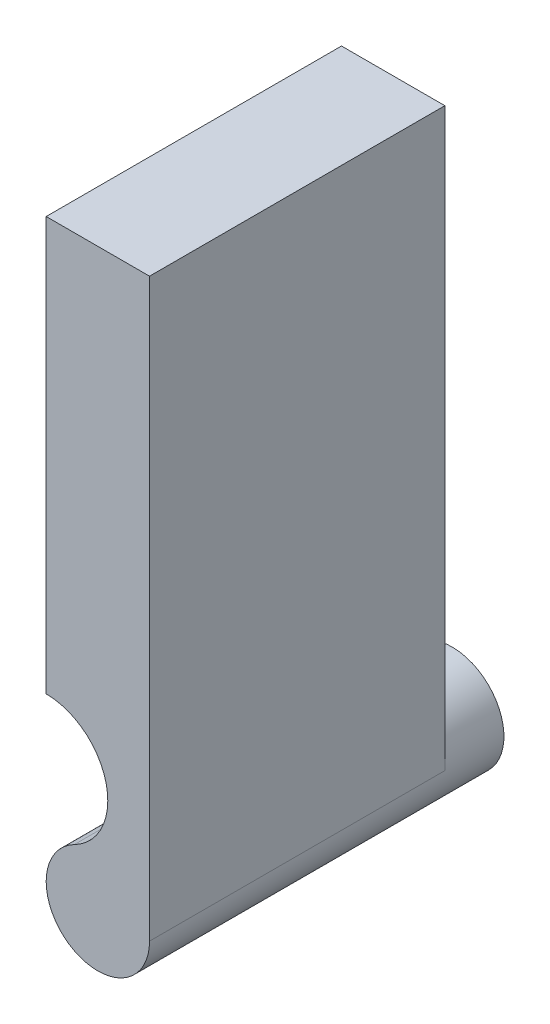
from build123d import *

# Parameters (mm, degrees)
DODANIE_WYCI_GNI_CIE1_DEPTH = 10
SZKIC2_R                    = 1.75
DODANIE_WYCI_GNI_CIE2_DEPTH = 2


with BuildPart() as part:
    # Szkic1 → Dodanie-wyciągnięcie1 (new body)
    with BuildSketch(Plane.XY):
        with BuildLine():
            Line((1.75, 0), (1.75, 19.5))
            Line((1.75, 19.5), (-1.75, 19.5))
            Line((-1.75, 19.5), (-1.75, 5.5))
            ThreePointArc((-1.75, 5.5), (0.277964608, 3.903301802), (-0.798314607, 1.557303371))
            ThreePointArc((-0.798314607, 1.557303371), (-0.912537517, -1.493243209), (1.75, 0))
        make_face()
    extrude(amount=DODANIE_WYCI_GNI_CIE1_DEPTH)

    # Szkic2 → Dodanie-wyciągnięcie2 (add)
    with BuildSketch(Plane(origin=(0, 0, 0), x_dir=(-1, 0, 0), z_dir=(0, 0, -1))):
        Circle(SZKIC2_R)
    extrude(amount=DODANIE_WYCI_GNI_CIE2_DEPTH)


solid = part.part
